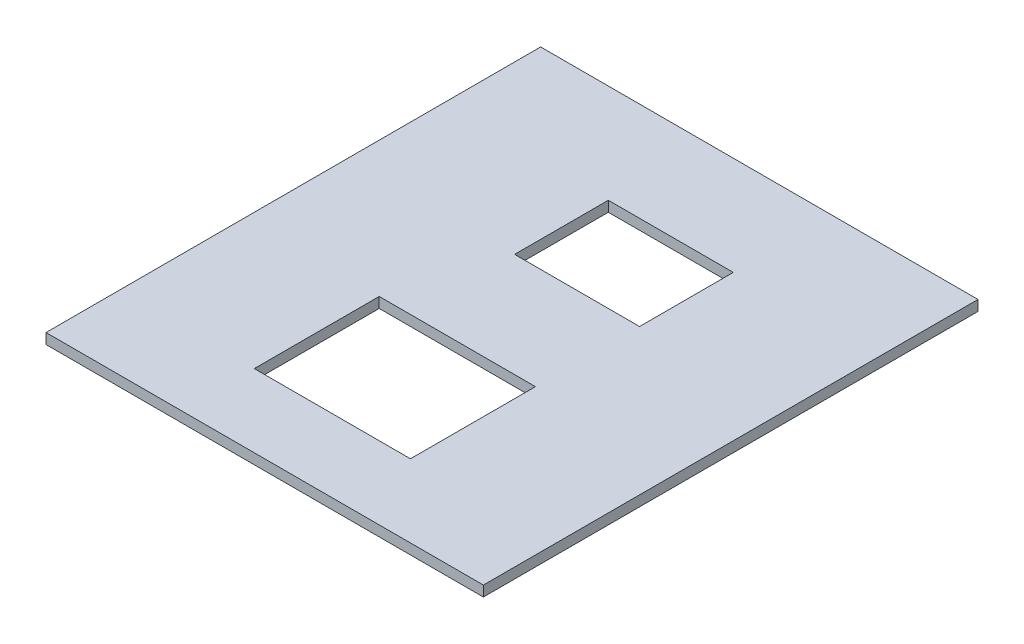
from build123d import *

# Parameters (mm, degrees)
SKETCH1_W           = 42
SKETCH1_H           = 47.5
BOSS_EXTRUDE1_DEPTH = 1
SKETCH2_W           = 15
SKETCH2_H           = 12
SKETCH2_W_2         = 12
SKETCH2_H_2         = 9
CUT_EXTRUDE3_DEPTH  = 25


with BuildPart() as part:
    # Sketch1 → Boss-Extrude1 (new body)
    with BuildSketch(Plane(origin=(0, 0, 0), x_dir=(1, 0, 0), z_dir=(0, 1, 0))):
        Rectangle(SKETCH1_W, SKETCH1_H)
    extrude(amount=BOSS_EXTRUDE1_DEPTH)

    # Sketch2 → Cut-Extrude3 (cut)
    with BuildSketch(Plane(origin=(0, 0, 0), x_dir=(1, 0, 0), z_dir=(0, 1, 0))):
        with Locations((-0.5, -10.75)):
            Rectangle(SKETCH2_W, SKETCH2_H)
        with Locations((1, 9.75)):
            Rectangle(SKETCH2_W_2, SKETCH2_H_2)
    extrude(amount=CUT_EXTRUDE3_DEPTH, mode=Mode.SUBTRACT)


solid = part.part
